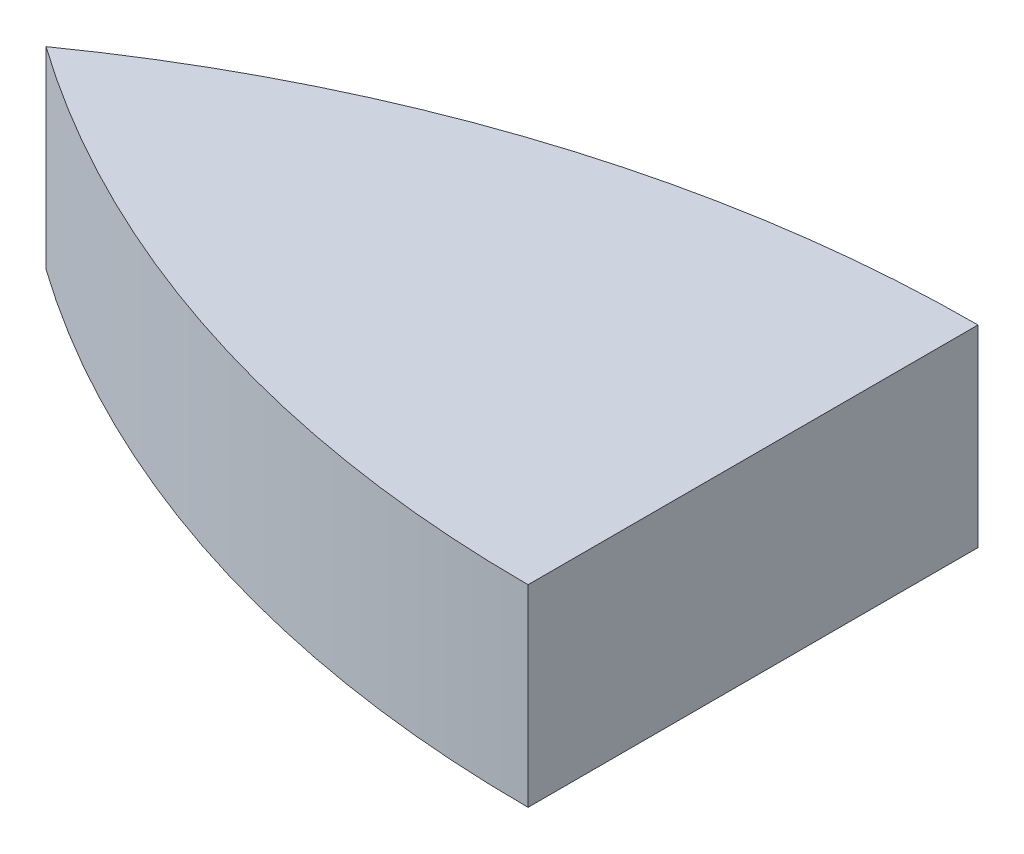
from build123d import *

# Parameters (mm, degrees)
BOSS_EXTRUDE1_DEPTH = 1.5


with BuildPart() as part:
    # Sketch2 → Boss-Extrude1 (new body)
    with BuildSketch(Plane(origin=(0, 0, 0), x_dir=(1, 0, 0), z_dir=(0, 1, 0))):
        with BuildLine():
            Line((13.261470886, 1.75), (13.261470886, -1.75))
            ThreePointArc((13.261470886, -1.75), (10.375621791, -1.301954299), (7.761470886, 0))
            ThreePointArc((7.761470886, 0), (10.375621791, 1.301954299), (13.261470886, 1.75))
        make_face()
    extrude(amount=BOSS_EXTRUDE1_DEPTH)


solid = part.part
